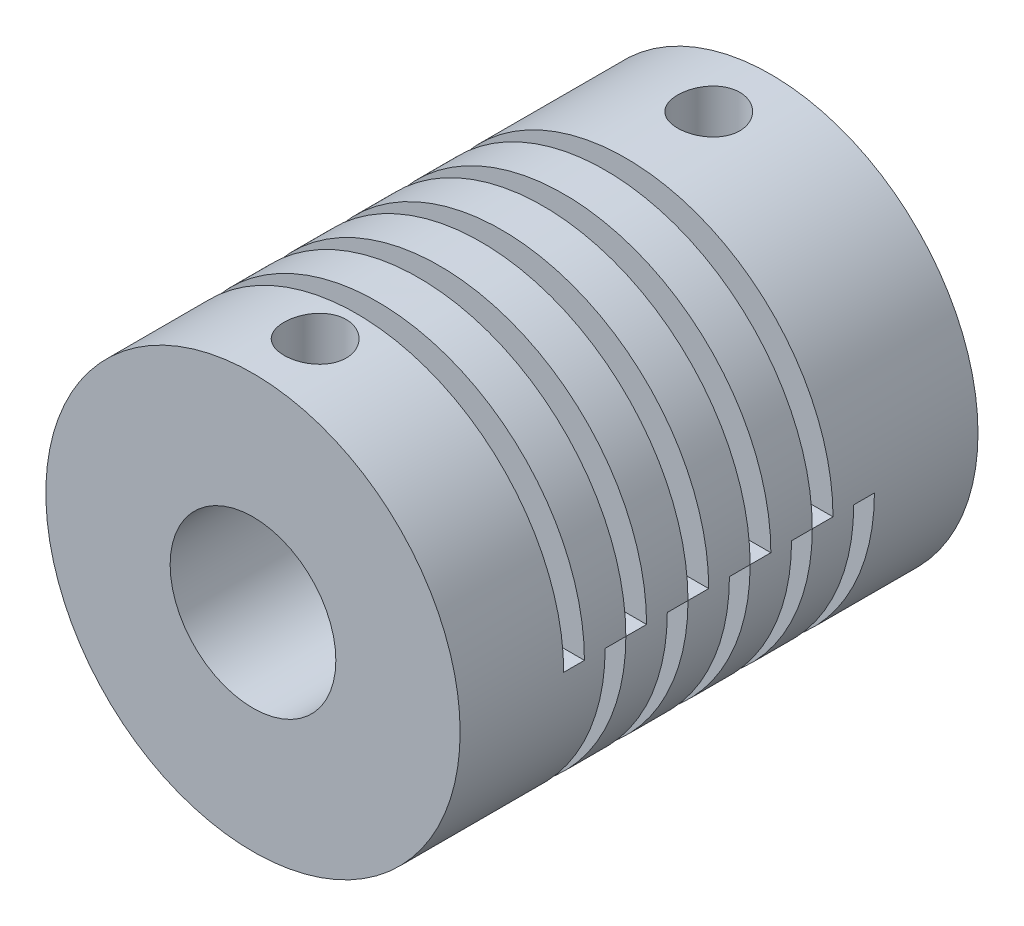
from build123d import *

# Parameters (mm, degrees)
SKETCH1_R           = 10
SKETCH1_R_2         = 4
BOSS_EXTRUDE1_DEPTH = 25
SKETCH2_W           = 1
SKETCH2_H           = 10
CUT_EXTRUDE1_DEPTH  = 25
LPATTERN1_COUNT     = 5
LPATTERN1_PITCH     = 3
CUT_EXTRUDE2_START  = 10
SKETCH3_R           = 1.5
CUT_EXTRUDE2_DEPTH  = 10


with BuildPart() as part:
    # Sketch1 → Boss-Extrude1 (new body)
    with BuildSketch(Plane.XY):
        Circle(SKETCH1_R)
        Circle(SKETCH1_R_2, mode=Mode.SUBTRACT)
    extrude(amount=BOSS_EXTRUDE1_DEPTH)

    # Sketch2 → Cut-Extrude1 (cut, symmetric)
    with BuildSketch(Plane(origin=(0, 0, 0), x_dir=(0, 0, -1), z_dir=(1, 0, 0))):
        with Locations((-19.5, 5)):
            Rectangle(SKETCH2_W, SKETCH2_H)
        with Locations((-17.5, -5)):
            Rectangle(SKETCH2_W, SKETCH2_H)
    cut_extrude1 = extrude(amount=CUT_EXTRUDE1_DEPTH, both=True, mode=Mode.SUBTRACT)

    # LPattern1: Cut-Extrude1 ×5
    with Locations(*[(0, 0, -i * LPATTERN1_PITCH) for i in range(1, LPATTERN1_COUNT)]):
        add(cut_extrude1, mode=Mode.SUBTRACT)

    # Sketch3 → Cut-Extrude2 (cut)
    with BuildSketch(Plane(origin=(0, 0, 0), x_dir=(1, 0, 0), z_dir=(0, 1, 0)).offset(CUT_EXTRUDE2_START)):
        with Locations((0, -3)):
            Circle(SKETCH3_R)
        with Locations((0, -22)):
            Circle(SKETCH3_R)
    extrude(amount=-CUT_EXTRUDE2_DEPTH, mode=Mode.SUBTRACT)


solid = part.part
